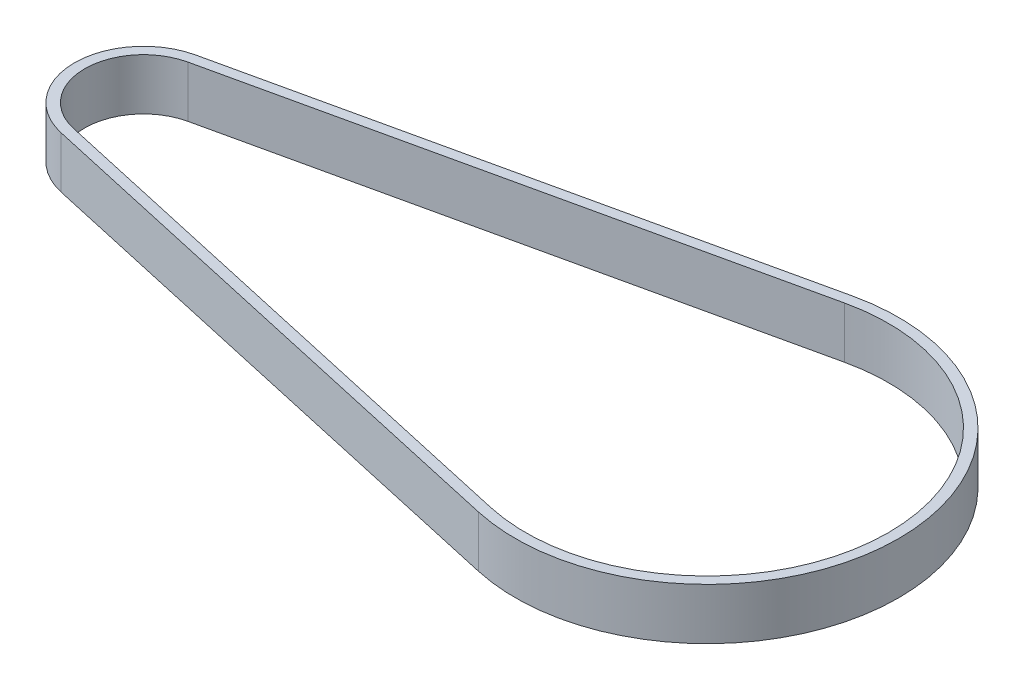
from build123d import *

# Parameters (mm, degrees)
LINEAR_AUSTRAGEN_D_NN1_DEPTH      = 2
LINEAR_AUSTRAGEN_D_NN1_DEPTH_BACK = 2


with BuildPart() as part:
    # Skizze1 → Linear-Austragen-D_nn1 (new body, two sides)
    with BuildSketch(Plane(origin=(0, 0, 0), x_dir=(1, 0, 0), z_dir=(0, 1, 0))) as linear_austragen_d_nn1_sk:
        with BuildLine():
            Line((40.65321754, -14.567567699), (-1.169276765, -5.246276474))
            ThreePointArc((-1.169276765, -5.246276474), (-5.375, 0), (-1.169276765, 5.246276474))
            Line((-1.169276765, 5.246276474), (40.65321754, 14.567567699))
            ThreePointArc((40.65321754, 14.567567699), (58.825, 0), (40.65321754, -14.567567699))
        make_face()
        with BuildLine():
            Line((40.827249431, -13.786726549), (-0.995244875, -4.465435325))
            ThreePointArc((-0.995244875, -4.465435325), (-4.575, 0), (-0.995244875, 4.465435325))
            Line((-0.995244875, 4.465435325), (40.827249431, 13.786726549))
            ThreePointArc((40.827249431, 13.786726549), (58.025, 0), (40.827249431, -13.786726549))
        make_face(mode=Mode.SUBTRACT)
    extrude(amount=LINEAR_AUSTRAGEN_D_NN1_DEPTH)
    extrude(linear_austragen_d_nn1_sk.sketch, amount=-LINEAR_AUSTRAGEN_D_NN1_DEPTH_BACK)


solid = part.part
